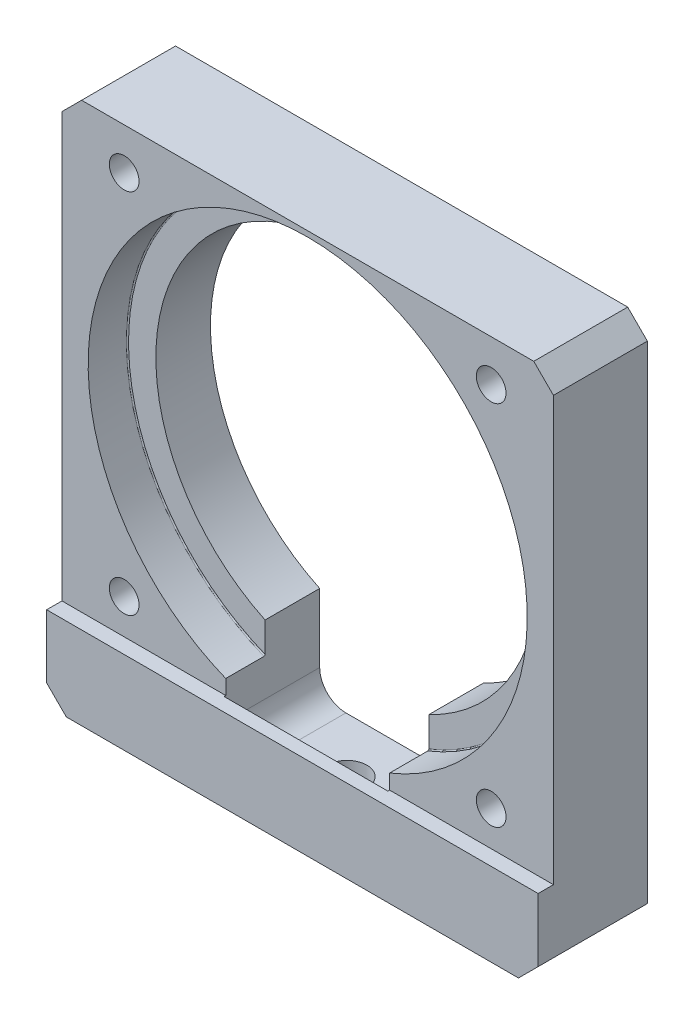
from build123d import *

# Parameters (mm, degrees)
SKETCH1_W                       = 57.15
SKETCH1_H                       = 61.214
BOSS_EXTRUDE1_DEPTH             = 6.35
SKETCH2_W                       = 57.15
SKETCH2_H                       = 51.562
CUT_EXTRUDE1_DEPTH              = 1.778
F_1_1_DIAMETER_HOLE1_D          = 44.45
CUT_EXTRUDE2_DEPTH              = 11.1252
F_14_0_182_DIAMETER_HOLE1_D     = 4.6228
F_14_0_182_DIAMETER_HOLE1_DEPTH = 13.97
F_14_0_182_DIAMETER_HOLE1_TIP   = 1.388829235
SKETCH10_R                      = 25.527
CUT_EXTRUDE3_DEPTH              = 4.572
CHAMFER1_SIZE                   = 2.286
F_8_32_TAPPED_HOLE1_D           = 3.4544
SKETCH13_W                      = 57.15
SKETCH13_H                      = 3.175
CUT_EXTRUDE4_DEPTH              = 2.286
FILLET1_R                       = 0.127


with BuildPart() as part:
    # Sketch1 → Boss-Extrude1 (new body, symmetric)
    with BuildSketch(Plane.XY):
        with Locations((28.575, 30.607)):
            Rectangle(SKETCH1_W, SKETCH1_H)
    extrude(amount=BOSS_EXTRUDE1_DEPTH, both=True)

    # Sketch2 → Cut-Extrude1 (cut)
    with BuildSketch(Plane.XY.offset(6.35)):
        with Locations((28.575, 35.433)):
            Rectangle(SKETCH2_W, SKETCH2_H)
    extrude(amount=-CUT_EXTRUDE1_DEPTH, mode=Mode.SUBTRACT)

    # 1 (1) Diameter Hole1 (through all)
    with Locations(Plane.XY.offset(4.572)):
        with Locations((28.575, 35.052)):
            Hole(F_1_1_DIAMETER_HOLE1_D / 2)

    # Sketch6 → Cut-Extrude2 (cut)
    with BuildSketch(Plane(origin=(0, 0, -6.35), x_dir=(-1, 0, 0), z_dir=(0, 0, -1))):
        with BuildLine():
            Line((-35.052, 3.9624), (-22.098, 3.9624))
            ThreePointArc((-22.098, 3.9624), (-19.942738531, 4.855138531), (-19.05, 7.0104))
            Line((-19.05, 7.0104), (-19.05, 20.953589203))
            Line((-19.05, 20.953589203), (-38.1, 20.953589203))
            Line((-38.1, 20.953589203), (-38.1, 7.0104))
            ThreePointArc((-38.1, 7.0104), (-37.207261469, 4.855138531), (-35.052, 3.9624))
        make_face()
    extrude(amount=-CUT_EXTRUDE2_DEPTH, mode=Mode.SUBTRACT)

    # #14 (0.182) Diameter Hole1
    with Locations(Plane(origin=(0, 3.9624, 0), x_dir=(-1, 0, 0), z_dir=(0, 1, 0))):
        with Locations((-28.575, 0)):
            Hole(F_14_0_182_DIAMETER_HOLE1_D / 2, depth=F_14_0_182_DIAMETER_HOLE1_DEPTH)
            with Locations((0, 0, -(F_14_0_182_DIAMETER_HOLE1_DEPTH + F_14_0_182_DIAMETER_HOLE1_TIP / 2))):  # 118° drill point
                Cone(0, F_14_0_182_DIAMETER_HOLE1_D / 2, F_14_0_182_DIAMETER_HOLE1_TIP, mode=Mode.SUBTRACT)

    # Sketch10 → Cut-Extrude3 (cut)
    with BuildSketch(Plane.XY.offset(4.572)):
        with Locations((28.575, 35.052)):
            Circle(SKETCH10_R)
    extrude(amount=-CUT_EXTRUDE3_DEPTH, mode=Mode.SUBTRACT)

    # Chamfer1
    chamfer1_edges = [part.edges().sort_by_distance(p)[0] for p in [
        (0, 61.214, -0.889),
        (57.15, 61.214, -0.889),
        (57.15, 0, 0),
        (0, 0, 0),
    ]]
    chamfer(chamfer1_edges, length=CHAMFER1_SIZE)

    # #8-32 Tapped Hole1 (through all)
    with Locations(Plane.XY.offset(4.572)):
        with Locations((7.239, 56.388), (49.911, 56.388), (7.239, 13.716), (49.911, 13.716)):
            Hole(F_8_32_TAPPED_HOLE1_D / 2)

    # Sketch13 → Cut-Extrude4 (cut)
    with BuildSketch(Plane.XZ):
        with Locations((28.575, -4.7625)):
            Rectangle(SKETCH13_W, SKETCH13_H)
    extrude(amount=-CUT_EXTRUDE4_DEPTH, mode=Mode.SUBTRACT)

    # Fillet1
    fillet1_edges = [part.edges().sort_by_distance(p)[0] for p in [
        (28.575, 60.579, 0),
    ]]
    fillet(fillet1_edges, radius=FILLET1_R)


solid = part.part
